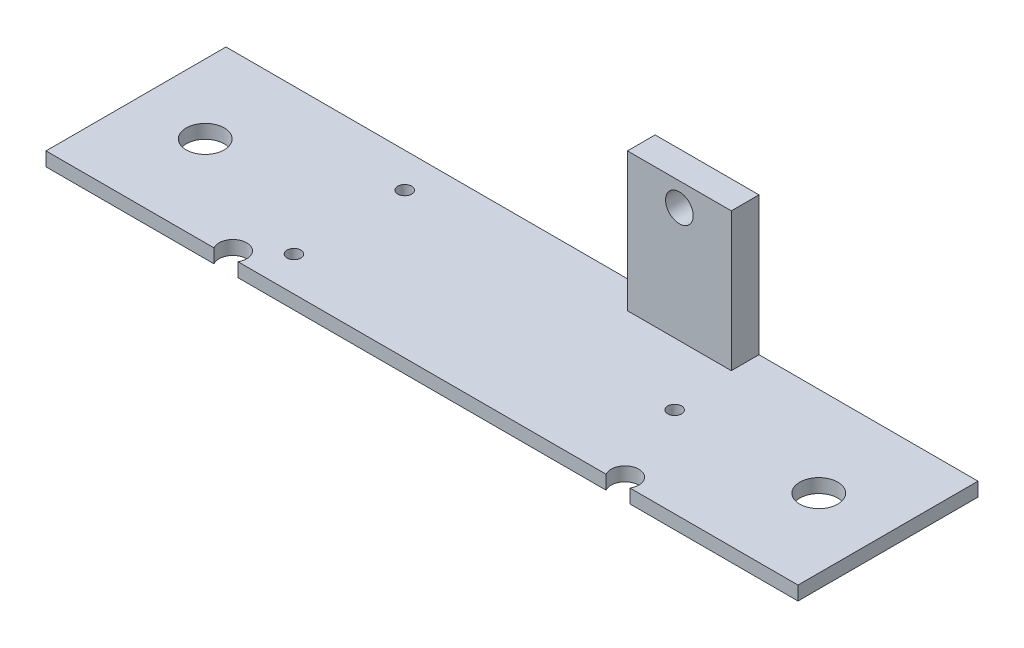
from build123d import *

# Parameters (mm, degrees)
SKETCH1_R           = 1
SKETCH1_R_2         = 2.75
BOSS_EXTRUDE1_DEPTH = 2
SKETCH2_W           = 15
SKETCH2_H           = 4
BOSS_EXTRUDE2_DEPTH = 20
SKETCH3_R           = 2
CUT_EXTRUDE1_DEPTH  = 20


with BuildPart() as part:
    # Sketch1 → Boss-Extrude1 (new body)
    with BuildSketch(Plane(origin=(0, 0, 0), x_dir=(1, 0, 0), z_dir=(0, 1, 0))):
        with BuildLine():
            Line((0, -26), (0, 0))
            Line((0, 0), (-32.806184042, 0))
            Line((-32.806184042, 0), (-47.806184042, 0))
            Line((-47.806184042, 0), (-108.64, 0))
            Line((-108.64, 0), (-108.64, -26))
            Line((-108.64, -26), (-84.372050808, -26))
            ThreePointArc((-84.372050808, -26), (-83.15763809, -23.068148347), (-80.64, -25))
            ThreePointArc((-80.64, -25), (-80.708148347, -25.51763809), (-80.907949192, -26))
            Line((-80.907949192, -26), (-27.732050808, -26))
            ThreePointArc((-27.732050808, -26), (-26.51763809, -23.068148347), (-24, -25))
            ThreePointArc((-24, -25), (-24.068148347, -25.51763809), (-24.267949192, -26))
            Line((-24.267949192, -26), (0, -26))
        make_face()
        with Locations((-77.82, -21)):
            Circle(SKETCH1_R, mode=Mode.SUBTRACT)
        with Locations((-98.64, -13)):
            Circle(SKETCH1_R_2, mode=Mode.SUBTRACT)
        with Locations((-77.82, -5)):
            Circle(SKETCH1_R, mode=Mode.SUBTRACT)
        with Locations((-30.82, -13)):
            Circle(SKETCH1_R, mode=Mode.SUBTRACT)
        with Locations((-10, -13)):
            Circle(SKETCH1_R_2, mode=Mode.SUBTRACT)
    extrude(amount=BOSS_EXTRUDE1_DEPTH)

    # Sketch2 → Boss-Extrude2 (add)
    with BuildSketch(Plane(origin=(0, 2, 0), x_dir=(1, 0, 0), z_dir=(0, 1, 0))):
        with Locations((-39.138364189, -2)):
            Rectangle(SKETCH2_W, SKETCH2_H)
    extrude(amount=BOSS_EXTRUDE2_DEPTH)

    # Sketch3 → Cut-Extrude1 (cut)
    with BuildSketch(Plane.XY.offset(4)):
        with Locations((-39.138364189, 18.622728592)):
            Circle(SKETCH3_R)
    extrude(amount=-CUT_EXTRUDE1_DEPTH, mode=Mode.SUBTRACT)


solid = part.part
